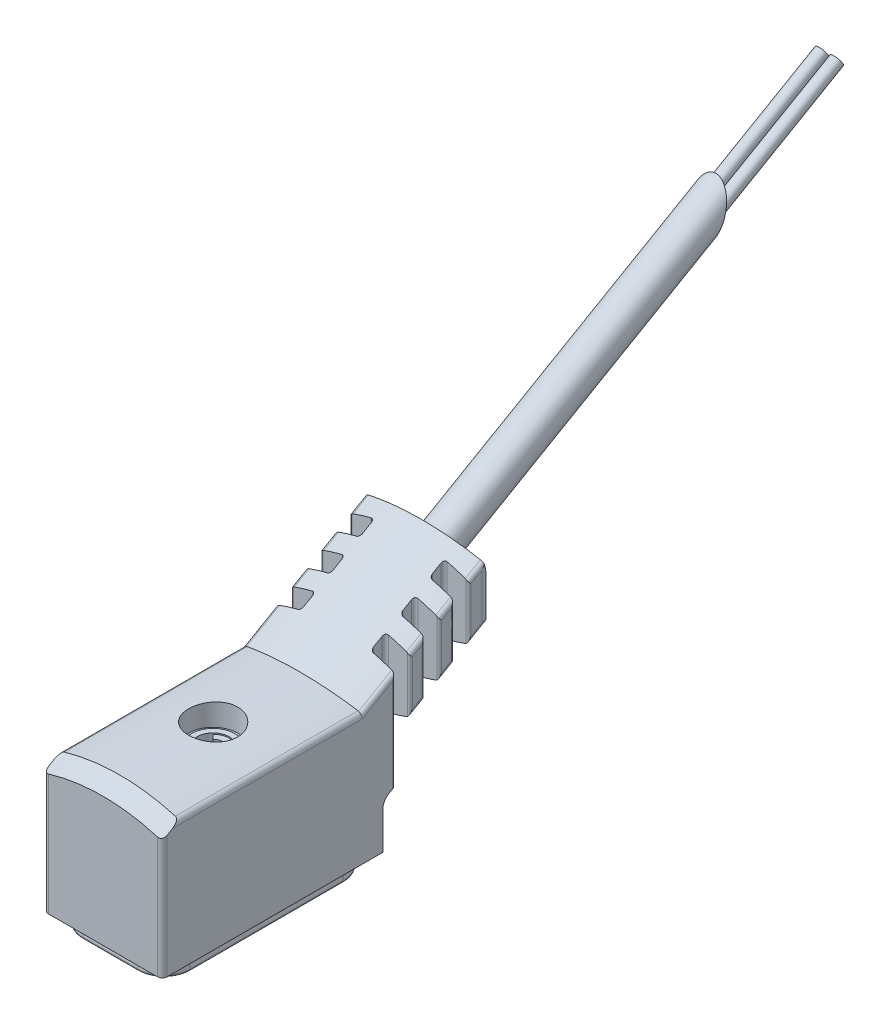
from build123d import *

# Parameters (mm, degrees)
BOSS_EXTRUDE1_DEPTH          = 4.85
BOSS_EXTRUDE1_DEPTH_BACK     = 4.85
CUT_EXTRUDE1_DEPTH           = 10
CUT_EXTRUDE1_DEPTH_BACK      = 10
SKETCH3_W                    = 16
SKETCH3_H                    = 25
CUT_EXTRUDE2_DEPTH           = 10
BOSS_EXTRUDE2_DEPTH          = 25
CUT_REVOLVE1_ANGLE           = 19
CUT_REVOLVE1_OTHER_WAY_ANGLE = 19
CUT_EXTRUDE3_DEPTH           = 5
CUT_EXTRUDE3_DEPTH_BACK      = 5
CUT_EXTRUDE4_DEPTH           = 18
BOSS_EXTRUDE3_DEPTH          = 4.45
BOSS_EXTRUDE3_DEPTH_BACK     = 4.45
CUT_EXTRUDE5_DEPTH           = 9
CUT_EXTRUDE5_DEPTH_BACK      = 9
SKETCH10_R                   = 1.45
BOSS_EXTRUDE4_DEPTH          = 50.5
CUT_EXTRUDE6_DEPTH           = 3
CUT_EXTRUDE6_DEPTH_BACK      = 3
CUT_REVOLVE2_ANGLE           = 90
CUT_EXTRUDE7_DEPTH           = 12.5
CUT_EXTRUDE8_DEPTH           = 6.45
CUT_EXTRUDE8_DEPTH_BACK      = 6.45
CUT_REVOLVE3_ANGLE           = 90
CUT_REVOLVE4_ANGLE           = 90
CUT_REVOLVE5_ANGLE           = 90
CUT_EXTRUDE9_DEPTH           = 2.25
CUT_EXTRUDE9_DEPTH_BACK      = 2.25
CUT_EXTRUDE10_DEPTH          = 12.5
BOSS_EXTRUDE5_DEPTH          = 1
BOSS_EXTRUDE6_DEPTH          = 1
CUT_EXTRUDE11_DEPTH          = 1.55
CUT_EXTRUDE11_DEPTH_BACK     = 1.55
CUT_EXTRUDE12_DEPTH          = 1.55
CUT_EXTRUDE12_DEPTH_BACK     = 1.55
SKETCH29_R                   = 0.5
BOSS_EXTRUDE7_DEPTH          = 50
SKETCH30_R                   = 0.5
BOSS_EXTRUDE8_DEPTH          = 50


with BuildPart() as part:
    # Sketch1 → Boss-Extrude1 (new, two sides: drawn at the far end of the back side and taken through both)
    with BuildSketch(Plane(origin=(0, 0, 0), x_dir=(0, 0, -1), z_dir=(1, 0, 0)).offset(-BOSS_EXTRUDE1_DEPTH_BACK)):
        with BuildLine():
            Line((-9.4, 11.35), (-9.4, 0))
            Line((-9.4, 0), (8.6, 0))
            Line((8.6, 0), (8.6, 3.045299462))
            ThreePointArc((8.6, 3.045299462), (8.733974596, 3.545299462), (9.1, 3.911324865))
            Line((9.1, 3.911324865), (9.6, 4.2))
            Line((9.6, 4.2), (9.6, 11.35))
            Line((9.6, 11.35), (-9.4, 11.35))
        make_face()
    extrude(amount=BOSS_EXTRUDE1_DEPTH + BOSS_EXTRUDE1_DEPTH_BACK)

    # Sketch2 → Cut-Extrude1 (cut, two sides: drawn at the far end of the back side and taken through both)
    with BuildSketch(Plane.XY.offset(0.2).offset(-CUT_EXTRUDE1_DEPTH_BACK)):
        with BuildLine():
            Line((-6, 15), (-6, 0))
            Line((-6, 0), (-4.85, 0))
            Line((-4.85, 0), (-4.85, 10.272913079))
            ThreePointArc((-4.85, 10.272913079), (-4.759910703, 10.543032101), (-4.525714286, 10.70499631))
            ThreePointArc((-4.525714286, 10.70499631), (0, 11.35), (4.525714286, 10.70499631))
            ThreePointArc((4.525714286, 10.70499631), (4.759910703, 10.543032101), (4.85, 10.272913079))
            Line((4.85, 10.272913079), (4.85, 0))
            Line((4.85, 0), (6, 0))
            Line((6, 0), (6, 15))
            Line((6, 15), (-6, 15))
        make_face()
    extrude(amount=CUT_EXTRUDE1_DEPTH + CUT_EXTRUDE1_DEPTH_BACK, mode=Mode.SUBTRACT)

    # Sketch3 → Cut-Extrude2 (cut)
    with BuildSketch(Plane(origin=(0, 0, 0), x_dir=(1, 0, 0), z_dir=(0, 1, 0))):
        with Locations((0, 0.3)):
            Rectangle(SKETCH3_W, SKETCH3_H)
        with BuildLine():
            Line((-4.45, -9.4), (4.45, -9.4))
            ThreePointArc((4.45, -9.4), (4.732842712, -9.282842712), (4.85, -9))
            Line((4.85, -9), (4.85, 9.4))
            ThreePointArc((4.85, 9.4), (4.791421356, 9.541421356), (4.65, 9.6))
            Line((4.65, 9.6), (-4.65, 9.6))
            ThreePointArc((-4.65, 9.6), (-4.791421356, 9.541421356), (-4.85, 9.4))
            Line((-4.85, 9.4), (-4.85, -9))
            ThreePointArc((-4.85, -9), (-4.732842712, -9.282842712), (-4.45, -9.4))
        make_face(mode=Mode.SUBTRACT)
    extrude(amount=CUT_EXTRUDE2_DEPTH, mode=Mode.SUBTRACT)

    # Sketch4 → Boss-Extrude2 (add)
    with BuildSketch(Plane(origin=(0, -0.08660254, 0.15), x_dir=(1, 0, 0), z_dir=(0, -0.49999999999999944, 0.8660254037844389))):
        with BuildLine():
            Line((4.85, 2.215695257), (4.85, 5.426304743))
            ThreePointArc((4.85, 5.426304743), (4.77308445, 5.66213612), (4.571917808, 5.807271996))
            ThreePointArc((4.571917808, 5.807271996), (0, 6.521), (-4.571917808, 5.807271996))
            ThreePointArc((-4.571917808, 5.807271996), (-4.77308445, 5.66213612), (-4.85, 5.426304743))
            Line((-4.85, 5.426304743), (-4.85, 2.215695257))
            ThreePointArc((-4.85, 2.215695257), (-4.77308445, 1.97986388), (-4.571917808, 1.834728004))
            ThreePointArc((-4.571917808, 1.834728004), (0, 1.121), (4.571917808, 1.834728004))
            ThreePointArc((4.571917808, 1.834728004), (4.77308445, 1.97986388), (4.85, 2.215695257))
        make_face()
    extrude(amount=-BOSS_EXTRUDE2_DEPTH)

    # Sketch5 → Cut-Revolve1 (revolve, cut)
    with BuildSketch(Plane(origin=(0, 0, 0), x_dir=(0, 0, -1), z_dir=(1, 0, 0))):
        Polygon((-9.4, 12.35), (-9.4, 10.55), (-6.282308546, 12.35), align=None)
    revolve(axis=Axis((0, -4.85, -1.8), (0, 0, -1)), revolution_arc=CUT_REVOLVE1_ANGLE, mode=Mode.SUBTRACT)

    # Sketch5 → Cut-Revolve1 other way (revolve, cut)
    with BuildSketch(Plane(origin=(0, 0, 0), x_dir=(0, 0, -1), z_dir=(1, 0, 0))):
        Polygon((-9.4, 12.35), (-9.4, 10.55), (-6.282308546, 12.35), align=None)
    revolve(axis=Axis((0, -4.85, -1.8), (0, 0, 1)), revolution_arc=CUT_REVOLVE1_OTHER_WAY_ANGLE, mode=Mode.SUBTRACT)

    # Sketch6 → Cut-Extrude3 (cut, two sides: drawn at the far end of the back side and taken through both)
    with BuildSketch(Plane(origin=(0, 0, 0), x_dir=(0, 0, -1), z_dir=(1, 0, 0)).offset(-CUT_EXTRUDE3_DEPTH_BACK)):
        Polygon((15.86366312, 19.240658889), (17.5, 14.516), (17.5, 5), (32.5, 5), (32.5, 20), (17.5, 20), align=None)
    extrude(amount=CUT_EXTRUDE3_DEPTH + CUT_EXTRUDE3_DEPTH_BACK, mode=Mode.SUBTRACT)

    # Sketch7 → Cut-Extrude4 (cut)
    with BuildSketch(Plane(origin=(0, 0, 0), x_dir=(1, 0, 0), z_dir=(0, 1, 0))):
        with BuildLine():
            Line((-6, 7.8), (-4.85, 7.8))
            Line((-4.85, 7.8), (-4.85, 9.4))
            ThreePointArc((-4.85, 9.4), (-4.791421356, 9.541421356), (-4.65, 9.6))
            Line((-4.65, 9.6), (-3.1, 9.6))
            ThreePointArc((-3.1, 9.6), (-2.923223305, 9.673223305), (-2.85, 9.85))
            Line((-2.85, 9.85), (-2.85, 10.55))
            ThreePointArc((-2.85, 10.55), (-2.923223305, 10.726776695), (-3.1, 10.8))
            Line((-3.1, 10.8), (-4.65, 10.8))
            ThreePointArc((-4.65, 10.8), (-4.791421356, 10.858578644), (-4.85, 11))
            Line((-4.85, 11), (-4.85, 11.8))
            ThreePointArc((-4.85, 11.8), (-4.791421356, 11.941421356), (-4.65, 12))
            Line((-4.65, 12), (-3.1, 12))
            ThreePointArc((-3.1, 12), (-2.923223305, 12.073223305), (-2.85, 12.25))
            Line((-2.85, 12.25), (-2.85, 12.95))
            ThreePointArc((-2.85, 12.95), (-2.923223305, 13.126776695), (-3.1, 13.2))
            Line((-3.1, 13.2), (-4.65, 13.2))
            ThreePointArc((-4.65, 13.2), (-4.791421356, 13.258578644), (-4.85, 13.4))
            Line((-4.85, 13.4), (-4.85, 14.2))
            ThreePointArc((-4.85, 14.2), (-4.791421356, 14.341421356), (-4.65, 14.4))
            Line((-4.65, 14.4), (-3.1, 14.4))
            ThreePointArc((-3.1, 14.4), (-2.923223305, 14.473223305), (-2.85, 14.65))
            Line((-2.85, 14.65), (-2.85, 15.35))
            ThreePointArc((-2.85, 15.35), (-2.923223305, 15.526776695), (-3.1, 15.6))
            Line((-3.1, 15.6), (-4.65, 15.6))
            ThreePointArc((-4.65, 15.6), (-4.791421356, 15.658578644), (-4.85, 15.8))
            Line((-4.85, 15.8), (-4.85, 16.7))
            ThreePointArc((-4.85, 16.7), (-4.615685425, 17.265685425), (-4.05, 17.5))
            Line((-4.05, 17.5), (4.05, 17.5))
            ThreePointArc((4.05, 17.5), (4.615685425, 17.265685425), (4.85, 16.7))
            Line((4.85, 16.7), (4.85, 15.8))
            ThreePointArc((4.85, 15.8), (4.791421356, 15.658578644), (4.65, 15.6))
            Line((4.65, 15.6), (3.1, 15.6))
            ThreePointArc((3.1, 15.6), (2.923223305, 15.526776695), (2.85, 15.35))
            Line((2.85, 15.35), (2.85, 14.65))
            ThreePointArc((2.85, 14.65), (2.923223305, 14.473223305), (3.1, 14.4))
            Line((3.1, 14.4), (4.65, 14.4))
            ThreePointArc((4.65, 14.4), (4.791421356, 14.341421356), (4.85, 14.2))
            Line((4.85, 14.2), (4.85, 13.4))
            ThreePointArc((4.85, 13.4), (4.791421356, 13.258578644), (4.65, 13.2))
            Line((4.65, 13.2), (3.1, 13.2))
            ThreePointArc((3.1, 13.2), (2.923223305, 13.126776695), (2.85, 12.95))
            Line((2.85, 12.95), (2.85, 12.25))
            ThreePointArc((2.85, 12.25), (2.923223305, 12.073223305), (3.1, 12))
            Line((3.1, 12), (4.65, 12))
            ThreePointArc((4.65, 12), (4.791421356, 11.941421356), (4.85, 11.8))
            Line((4.85, 11.8), (4.85, 11))
            ThreePointArc((4.85, 11), (4.791421356, 10.858578644), (4.65, 10.8))
            Line((4.65, 10.8), (3.1, 10.8))
            ThreePointArc((3.1, 10.8), (2.923223305, 10.726776695), (2.85, 10.55))
            Line((2.85, 10.55), (2.85, 9.85))
            ThreePointArc((2.85, 9.85), (2.923223305, 9.673223305), (3.1, 9.6))
            Line((3.1, 9.6), (4.65, 9.6))
            ThreePointArc((4.65, 9.6), (4.791421356, 9.541421356), (4.85, 9.4))
            Line((4.85, 9.4), (4.85, 7.8))
            Line((4.85, 7.8), (6, 7.8))
            Line((6, 7.8), (6, 19.8))
            Line((6, 19.8), (-6, 19.8))
            Line((-6, 19.8), (-6, 7.8))
        make_face()
    extrude(amount=CUT_EXTRUDE4_DEPTH, mode=Mode.SUBTRACT)

    # Sketch8 → Boss-Extrude3 (add, two sides: drawn at the far end of the back side and taken through both)
    with BuildSketch(Plane(origin=(0, 0, 0), x_dir=(0, 0, -1), z_dir=(1, 0, 0)).offset(-BOSS_EXTRUDE3_DEPTH_BACK)):
        Polygon((-8.826326981, -1), (8.026326981, -1), (7.85, 0), (-8.65, 0), align=None)
    extrude(amount=BOSS_EXTRUDE3_DEPTH + BOSS_EXTRUDE3_DEPTH_BACK)

    # Sketch9 → Cut-Extrude5 (cut, two sides: drawn at the far end of the back side and taken through both)
    with BuildSketch(Plane.XY.offset(0.2).offset(-CUT_EXTRUDE5_DEPTH_BACK)):
        Polygon((-6, -3), (6, -3), (6, 0), (4.25, 0), (4.426326981, -1), (-4.426326981, -1), (-4.25, 0), (-6, 0), align=None)
    extrude(amount=CUT_EXTRUDE5_DEPTH + CUT_EXTRUDE5_DEPTH_BACK, mode=Mode.SUBTRACT)

    # Sketch10 → Boss-Extrude4 (add)
    with BuildSketch(Plane(origin=(0, -0.08660254, 0.15), x_dir=(1, 0, 0), z_dir=(0, -0.49999999999999944, 0.8660254037844389))):
        with Locations((0, 3.821)):
            Circle(SKETCH10_R)
    extrude(amount=-BOSS_EXTRUDE4_DEPTH)

    # Sketch11 → Cut-Extrude6 (cut, two sides: drawn at the far end of the back side and taken through both)
    with BuildSketch(Plane(origin=(0, 0, 0), x_dir=(0, 0, -1), z_dir=(1, 0, 0)).offset(-CUT_EXTRUDE6_DEPTH_BACK)):
        Polygon((37.379798567, 20.603073792), (42.078261671, 18.892973076), (45.498463104, 28.289899283), (40.8, 30), align=None)
    extrude(amount=CUT_EXTRUDE6_DEPTH + CUT_EXTRUDE6_DEPTH_BACK, mode=Mode.SUBTRACT)

    # Sketch12 → Cut-Revolve2 (revolve, cut)
    with BuildSketch(Plane.XY.offset(6.65)):
        with BuildLine():
            Line((-2.25, -3), (-6, -3))
            Line((-6, -3), (-6, 0))
            Line((-6, 0), (-4.25, 0))
            Line((-4.25, 0), (-4.395285105, -0.823952773))
            ThreePointArc((-4.395285105, -0.823952773), (-4.362470608, -0.946418141), (-4.247563942, -1))
            Line((-4.247563942, -1), (-2.25, -1))
            Line((-2.25, -1), (-2.25, -3))
        make_face()
    revolve(axis=Axis((-2.25, -1, 6.65), (0, 1, 0)), revolution_arc=CUT_REVOLVE2_ANGLE, mode=Mode.SUBTRACT)

    # Sketch13 → Cut-Extrude7 (cut)
    with BuildSketch(Plane.XY.offset(-5.85)):
        with BuildLine():
            Line((-6, -3), (6, -3))
            Line((6, -3), (6, 0))
            Line((6, 0), (4.25, 0))
            Line((4.25, 0), (4.395285105, -0.823952773))
            ThreePointArc((4.395285105, -0.823952773), (4.362470608, -0.946418141), (4.247563942, -1))
            Line((4.247563942, -1), (-4.247563942, -1))
            ThreePointArc((-4.247563942, -1), (-4.362470608, -0.946418141), (-4.395285105, -0.823952773))
            Line((-4.395285105, -0.823952773), (-4.25, 0))
            Line((-4.25, 0), (-6, 0))
            Line((-6, 0), (-6, -3))
        make_face()
    extrude(amount=CUT_EXTRUDE7_DEPTH, mode=Mode.SUBTRACT)

    # Sketch14 → Cut-Extrude8 (cut, two sides: drawn at the far end of the back side and taken through both)
    with BuildSketch(Plane(origin=(0, 0, 0), x_dir=(0, 0, -1), z_dir=(1, 0, 0)).offset(-CUT_EXTRUDE8_DEPTH_BACK)):
        with BuildLine():
            Line((-10.2, -2), (9.8, -2))
            Line((9.8, -2), (9.8, 0))
            Line((9.8, 0), (7.85, 0))
            Line((7.85, 0), (7.995285105, -0.823952773))
            ThreePointArc((7.995285105, -0.823952773), (7.962470608, -0.946418141), (7.847563942, -1))
            Line((7.847563942, -1), (-8.647563942, -1))
            ThreePointArc((-8.647563942, -1), (-8.762470608, -0.946418141), (-8.795285105, -0.823952773))
            Line((-8.795285105, -0.823952773), (-8.65, 0))
            Line((-8.65, 0), (-10.2, 0))
            Line((-10.2, 0), (-10.2, -2))
        make_face()
    extrude(amount=CUT_EXTRUDE8_DEPTH + CUT_EXTRUDE8_DEPTH_BACK, mode=Mode.SUBTRACT)

    # Sketch15 → Cut-Revolve3 (revolve, cut)
    with BuildSketch(Plane.XY.offset(6.65)):
        with BuildLine():
            Line((2.25, -1), (4.247563942, -1))
            ThreePointArc((4.247563942, -1), (4.362470608, -0.946418141), (4.395285105, -0.823952773))
            Line((4.395285105, -0.823952773), (4.25, 0))
            Line((4.25, 0), (6, 0))
            Line((6, 0), (6, -3))
            Line((6, -3), (2.25, -3))
            Line((2.25, -3), (2.25, -1))
        make_face()
    revolve(axis=Axis((2.25, -3, 6.65), (0, -1, 0)), revolution_arc=CUT_REVOLVE3_ANGLE, mode=Mode.SUBTRACT)

    # Sketch16 → Cut-Revolve4 (revolve, cut)
    with BuildSketch(Plane.XY.offset(-5.85)):
        with BuildLine():
            Line((2.25, -1), (4.247563942, -1))
            ThreePointArc((4.247563942, -1), (4.362470608, -0.946418141), (4.395285105, -0.823952773))
            Line((4.395285105, -0.823952773), (4.25, 0))
            Line((4.25, 0), (6, 0))
            Line((6, 0), (6, -3))
            Line((6, -3), (2.25, -3))
            Line((2.25, -3), (2.25, -1))
        make_face()
    revolve(axis=Axis((2.25, -3, -5.85), (0, 1, 0)), revolution_arc=CUT_REVOLVE4_ANGLE, mode=Mode.SUBTRACT)

    # Sketch17 → Cut-Revolve5 (revolve, cut)
    with BuildSketch(Plane.XY.offset(-5.85)):
        with BuildLine():
            Line((-2.25, -3), (-6, -3))
            Line((-6, -3), (-6, 0))
            Line((-6, 0), (-4.25, 0))
            Line((-4.25, 0), (-4.395285105, -0.823952773))
            ThreePointArc((-4.395285105, -0.823952773), (-4.362470608, -0.946418141), (-4.247563942, -1))
            Line((-4.247563942, -1), (-2.25, -1))
            Line((-2.25, -1), (-2.25, -3))
        make_face()
    revolve(axis=Axis((-2.25, -1, -5.85), (0, -1, 0)), revolution_arc=CUT_REVOLVE5_ANGLE, mode=Mode.SUBTRACT)

    # Sketch18 → Cut-Extrude9 (cut, two sides: drawn at the far end of the back side and taken through both)
    with BuildSketch(Plane(origin=(0, 0, 0), x_dir=(0, 0, -1), z_dir=(1, 0, 0)).offset(-CUT_EXTRUDE9_DEPTH_BACK)):
        with BuildLine():
            Line((-8.616812048, -1), (7.816812048, -1))
            ThreePointArc((7.816812048, -1), (7.764419032, -0.985176123), (7.727559369, -0.945099438))
            Line((7.727559369, -0.945099438), (7.25, 0))
            Line((7.25, 0), (-8.05, 0))
            Line((-8.05, 0), (-8.527559369, -0.945099438))
            ThreePointArc((-8.527559369, -0.945099438), (-8.564419032, -0.985176123), (-8.616812048, -1))
        make_face()
    extrude(amount=CUT_EXTRUDE9_DEPTH + CUT_EXTRUDE9_DEPTH_BACK, mode=Mode.SUBTRACT)

    # Sketch19 → Cut-Extrude10 (cut)
    with BuildSketch(Plane.XY.offset(-5.85)):
        with BuildLine():
            Line((-4.216812048, -1), (4.216812048, -1))
            ThreePointArc((4.216812048, -1), (4.164419032, -0.985176123), (4.127559369, -0.945099438))
            Line((4.127559369, -0.945099438), (3.65, 0))
            Line((3.65, 0), (-3.65, 0))
            Line((-3.65, 0), (-4.127559369, -0.945099438))
            ThreePointArc((-4.127559369, -0.945099438), (-4.164419032, -0.985176123), (-4.216812048, -1))
        make_face()
    extrude(amount=CUT_EXTRUDE10_DEPTH, mode=Mode.SUBTRACT)

    # Sketch20 → Cut-Revolve6 (revolve, cut)
    with BuildSketch(Plane.XY.offset(6.65)):
        with BuildLine():
            Line((-2.25, -1), (-4.216812048, -1))
            ThreePointArc((-4.216812048, -1), (-4.164419032, -0.985176123), (-4.127559369, -0.945099438))
            Line((-4.127559369, -0.945099438), (-3.65, 0))
            Line((-3.65, 0), (-2.25, 0))
            Line((-2.25, 0), (-2.25, -1))
        make_face()
    revolve(axis=Axis((-2.25, 0, 6.65), (0, -1, 0)), mode=Mode.SUBTRACT)

    # Sketch21 → Cut-Revolve7 (revolve, cut)
    with BuildSketch(Plane.XY.offset(6.65)):
        with BuildLine():
            Line((2.25, 0), (3.65, 0))
            Line((3.65, 0), (4.127559369, -0.945099438))
            ThreePointArc((4.127559369, -0.945099438), (4.164419032, -0.985176123), (4.216812048, -1))
            Line((4.216812048, -1), (2.25, -1))
            Line((2.25, -1), (2.25, 0))
        make_face()
    revolve(axis=Axis((2.25, -1, 6.65), (0, 1, 0)), mode=Mode.SUBTRACT)

    # Sketch22 → Cut-Revolve8 (revolve, cut)
    with BuildSketch(Plane.XY.offset(-5.85)):
        with BuildLine():
            Line((-2.25, -1), (-4.216812048, -1))
            ThreePointArc((-4.216812048, -1), (-4.164419032, -0.985176123), (-4.127559369, -0.945099438))
            Line((-4.127559369, -0.945099438), (-3.65, 0))
            Line((-3.65, 0), (-2.25, 0))
            Line((-2.25, 0), (-2.25, -1))
        make_face()
    revolve(axis=Axis((-2.25, 0, -5.85), (0, -1, 0)), mode=Mode.SUBTRACT)

    # Sketch23 → Cut-Revolve9 (revolve, cut)
    with BuildSketch(Plane.XY.offset(-5.85)):
        with BuildLine():
            Line((2.25, 0), (3.65, 0))
            Line((3.65, 0), (4.127559369, -0.945099438))
            ThreePointArc((4.127559369, -0.945099438), (4.164419032, -0.985176123), (4.216812048, -1))
            Line((4.216812048, -1), (2.25, -1))
            Line((2.25, -1), (2.25, 0))
        make_face()
    revolve(axis=Axis((2.25, -1, -5.85), (0, 1, 0)), mode=Mode.SUBTRACT)

    # Sketch24 → Cut-Revolve10 (revolve, cut)
    with BuildSketch(Plane(origin=(0, 0, 0), x_dir=(0, 0, -1), z_dir=(1, 0, 0))):
        Polygon((-0.4, 0), (-2.5, 0), (-2.46508987, 2), (-1.542511844, 2), (-1.45, 7.3), (-1.45, 8.5), (-1.7, 8.5), (-1.7, 9.6), (-2.15, 9.6), (-2.2, 9.55), (-2.2, 9.5), (-2.4, 9.5), (-2.4, 11.35), (-0.4, 11.35), align=None)
    revolve(axis=Axis((0, 11.35, 0.4), (0, -1, 0)), mode=Mode.SUBTRACT)

    # Sketch25 → Boss-Extrude5 (add)
    with BuildSketch(Plane(origin=(0, 8.5, 0), x_dir=(1, 0, 0), z_dir=(0, 1, 0))):
        with BuildLine():
            Line((-1.060660172, 0.660660172), (-0.565685425, 0.165685425))
            ThreePointArc((-0.565685425, 0.165685425), (0, 0.4), (0.565685425, 0.165685425))
            Line((0.565685425, 0.165685425), (1.060660172, 0.660660172))
            ThreePointArc((1.060660172, 0.660660172), (0, 1.1), (-1.060660172, 0.660660172))
        make_face()
    extrude(amount=BOSS_EXTRUDE5_DEPTH)

    # Sketch26 → Boss-Extrude6 (add)
    with BuildSketch(Plane(origin=(0, 8.5, 0), x_dir=(1, 0, 0), z_dir=(0, 1, 0))):
        with BuildLine():
            Line((1.060660172, -1.460660172), (0.565685425, -0.965685425))
            ThreePointArc((0.565685425, -0.965685425), (0, -1.2), (-0.565685425, -0.965685425))
            Line((-0.565685425, -0.965685425), (-1.060660172, -1.460660172))
            ThreePointArc((-1.060660172, -1.460660172), (0, -1.9), (1.060660172, -1.460660172))
        make_face()
    extrude(amount=BOSS_EXTRUDE6_DEPTH)

    # Sketch27 → Cut-Extrude11 (cut, two sides: drawn at the far end of the back side and taken through both)
    with BuildSketch(Plane.XY.offset(4.65).offset(-CUT_EXTRUDE11_DEPTH_BACK)):
        Polygon((-0.5, 0), (0.5, 0), (0.309175548, 0.524285873), (0.4065, 6.1), (-0.4065, 6.1), (-0.309175548, 0.524285873), align=None)
    extrude(amount=CUT_EXTRUDE11_DEPTH + CUT_EXTRUDE11_DEPTH_BACK, mode=Mode.SUBTRACT)

    # Sketch28 → Cut-Extrude12 (cut, two sides: drawn at the far end of the back side and taken through both)
    with BuildSketch(Plane.XY.offset(-3.85).offset(-CUT_EXTRUDE12_DEPTH_BACK)):
        Polygon((-0.5, 0), (0.5, 0), (0.309175548, 0.524285873), (0.4065, 6.1), (-0.4065, 6.1), (-0.309175548, 0.524285873), align=None)
    extrude(amount=CUT_EXTRUDE12_DEPTH + CUT_EXTRUDE12_DEPTH_BACK, mode=Mode.SUBTRACT)

    # Sketch29 → Boss-Extrude7 (add)
    with BuildSketch(Plane(origin=(0, 4.91339746, -8.510254038), x_dir=(1, 0, 0), z_dir=(0, -0.49999999999999944, 0.8660254037844389))):
        with Locations((0.6, 3.821)):
            Circle(SKETCH29_R)
    extrude(amount=-BOSS_EXTRUDE7_DEPTH)

    # Sketch30 → Boss-Extrude8 (add)
    with BuildSketch(Plane(origin=(0, 4.91339746, -8.510254038), x_dir=(1, 0, 0), z_dir=(0, -0.49999999999999944, 0.8660254037844389))):
        with Locations((-0.6, 3.821)):
            Circle(SKETCH30_R)
    extrude(amount=-BOSS_EXTRUDE8_DEPTH)


solid = part.part
